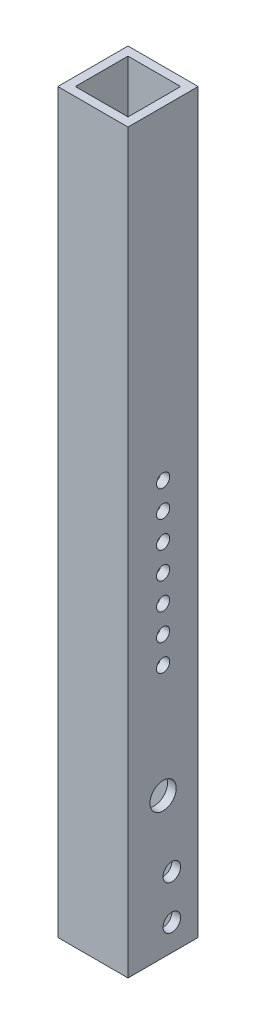
from build123d import *

# Parameters (mm, degrees)
SKETCH1_W                = 25.4
SKETCH1_H                = 25.4
SKETCH1_W_2              = 19.05
SKETCH1_H_2              = 19.05
BOSS_EXTRUDE1_DEPTH      = 228.6
BOSS_EXTRUDE1_DEPTH_BACK = 38.1
CUT_EXTRUDE2_REACH       = 27.4
SKETCH3_W                = 10.16
SKETCH3_H                = 76.2
SKETCH4_R                = 3.175
SKETCH4_R_2              = 2.38125
SKETCH4_R_3              = 4.7625
CUT_EXTRUDE3_DEPTH       = 26.4


with BuildPart() as part:
    # Sketch1 → Boss-Extrude1 (new body, two sides)
    with BuildSketch(Plane(origin=(0, 0, 0), x_dir=(1, 0, 0), z_dir=(0, 1, 0))) as boss_extrude1_sk:
        Rectangle(SKETCH1_W, SKETCH1_H)
        Rectangle(SKETCH1_W_2, SKETCH1_H_2, mode=Mode.SUBTRACT)
    extrude(amount=BOSS_EXTRUDE1_DEPTH)
    extrude(boss_extrude1_sk.sketch, amount=-BOSS_EXTRUDE1_DEPTH_BACK)

    # Sketch3 → Cut-Extrude2 (cut, up to next)
    with BuildSketch(Plane(origin=(0, 0, -12.7), x_dir=(-1, 0, 0), z_dir=(0, 0, -1)), mode=Mode.PRIVATE) as cut_extrude2_sk1:
        with Locations((0, 82.55)):
            Rectangle(SKETCH3_W, SKETCH3_H)
    cut_extrude2_tool1 = extrude(cut_extrude2_sk1.sketch, amount=-CUT_EXTRUDE2_REACH, mode=Mode.PRIVATE) & part.part
    add(cut_extrude2_tool1.solids().sort_by_distance((0, 82.55, -12.7))[0], mode=Mode.SUBTRACT)

    # Sketch4 → Cut-Extrude3 (cut, through all)
    with BuildSketch(Plane(origin=(12.7, 0, 0), x_dir=(0, 0, -1), z_dir=(1, 0, 0))):
        with Locations((3.175, -28.575)):
            Circle(SKETCH4_R)
        with Locations((3.175, -12.7)):
            Circle(SKETCH4_R)
        with Locations((0, 63.246)):
            Circle(SKETCH4_R_2)
        with Locations((0, 72.898)):
            Circle(SKETCH4_R_2)
        with Locations((0, 82.55)):
            Circle(SKETCH4_R_2)
        with Locations((0, 101.854)):
            Circle(SKETCH4_R_2)
        with Locations((0, 111.506)):
            Circle(SKETCH4_R_2)
        with Locations((0, 12.7)):
            Circle(SKETCH4_R_3)
        with Locations((0, 53.594)):
            Circle(SKETCH4_R_2)
        with Locations((0, 92.202)):
            Circle(SKETCH4_R_2)
    extrude(amount=-CUT_EXTRUDE3_DEPTH, mode=Mode.SUBTRACT)


solid = part.part
